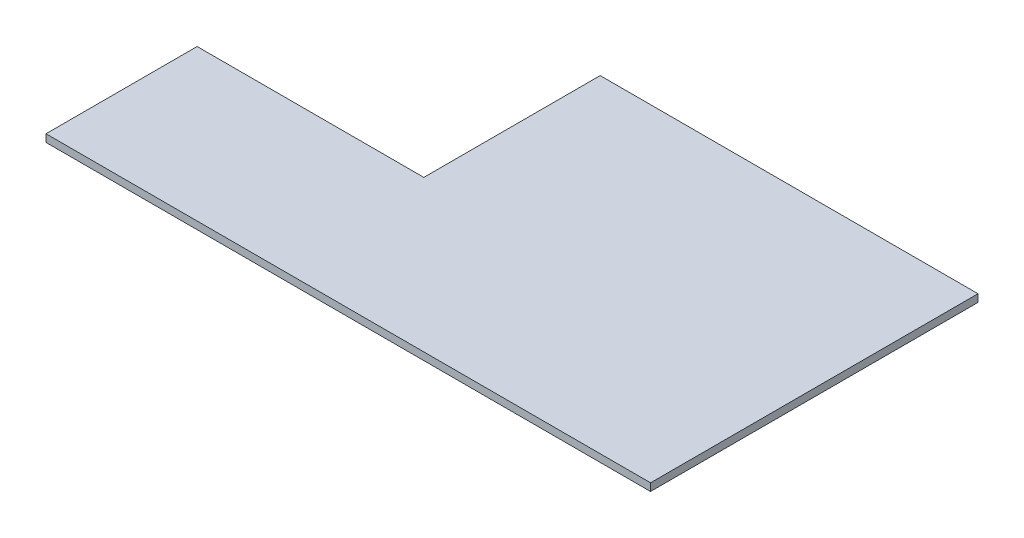
from build123d import *

# Parameters (mm, degrees)
BOSS_EXTRUDE1_DEPTH = 3


with BuildPart() as part:
    # Sketch1 → Boss-Extrude1 (new body)
    with BuildSketch(Plane(origin=(0, 0, 0), x_dir=(1, 0, 0), z_dir=(0, 1, 0))):
        Polygon((-120, 3.426061493), (120, 3.426061493), (120, 130.27818448), (120, 133.426061493), (-30, 133.426061493), (-30, 63.426061493), (-120, 63.426061493), align=None)
    extrude(amount=BOSS_EXTRUDE1_DEPTH)


solid = part.part
